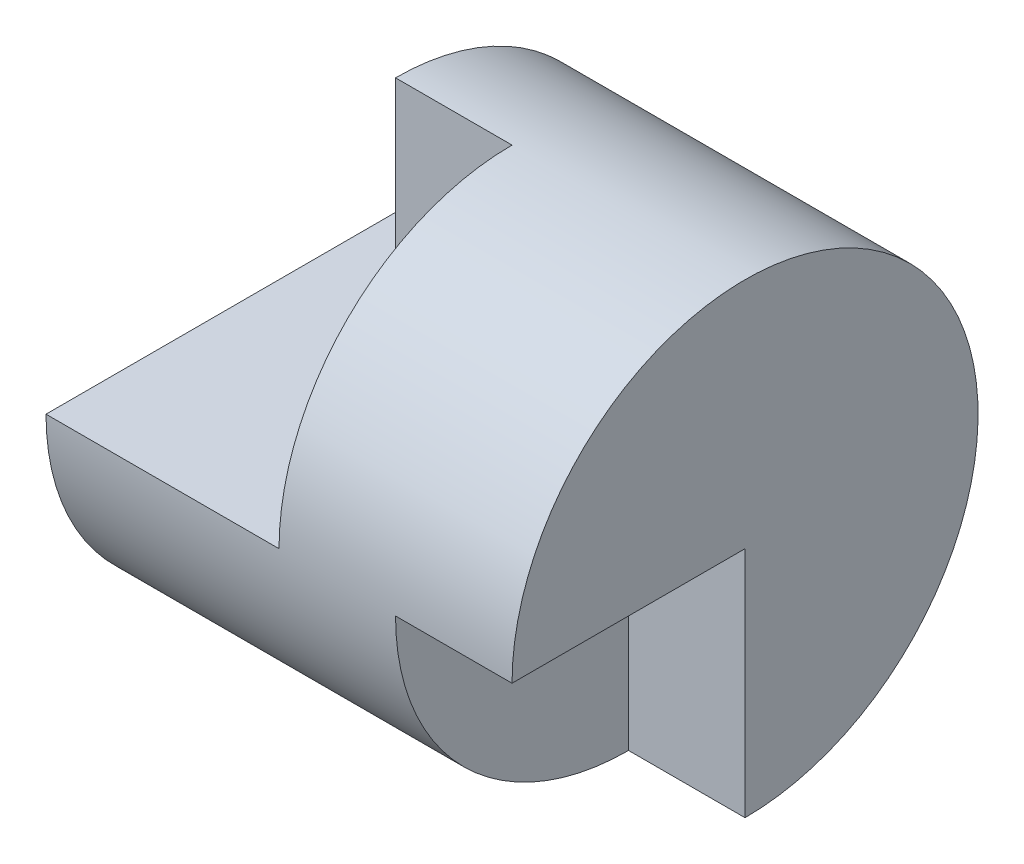
from build123d import *

# Parameters (mm, degrees)
SKETCH5_W           = 4
SKETCH5_H           = 2
SKETCH6_W           = 1
SKETCH6_H           = 2
CUT_EXTRUDE5_DEPTH  = 11
SKETCH8_W           = 0.5
SKETCH8_H           = 2
CUT_EXTRUDE7_DEPTH  = 10
SKETCH9_W           = 1.5
SKETCH9_H           = 2
CUT_EXTRUDE8_DEPTH  = 10
BOSS_EXTRUDE1_DEPTH = 1
SKETCH12_W          = 2.133602388
SKETCH12_H          = 2.324631101
CUT_EXTRUDE9_DEPTH  = 1


with BuildPart() as part:
    # Sketch5 → Revolve-Thin2 (revolve)
    with BuildSketch(Plane.XY):
        with Locations((2, 1)):
            Rectangle(SKETCH5_W, SKETCH5_H)
    revolve(axis=Axis((0, 0, 0), (1, 0, 0)))

    # Sketch6 → Cut-Extrude5 (cut)
    with BuildSketch(Plane.XY):
        with Locations((3.5, 1)):
            Rectangle(SKETCH6_W, SKETCH6_H)
        with Locations((0.5, 1)):
            Rectangle(SKETCH6_W, SKETCH6_H)
    extrude(amount=-CUT_EXTRUDE5_DEPTH, mode=Mode.SUBTRACT)

    # Sketch8 → Cut-Extrude7 (cut)
    with BuildSketch(Plane(origin=(0, 0, 0), x_dir=(-1, 0, 0), z_dir=(0, 0, -1))):
        with Locations((-0.25, 1)):
            Rectangle(SKETCH8_W, SKETCH8_H)
    extrude(amount=-CUT_EXTRUDE7_DEPTH, mode=Mode.SUBTRACT)

    # Sketch9 → Cut-Extrude8 (cut)
    with BuildSketch(Plane(origin=(0, 0, 0), x_dir=(-1, 0, 0), z_dir=(0, 0, -1))):
        with Locations((-1.25, 1)):
            Rectangle(SKETCH9_W, SKETCH9_H)
    extrude(amount=-CUT_EXTRUDE8_DEPTH, mode=Mode.SUBTRACT)

    # Sketch10 → Boss-Extrude1 (add)
    with BuildSketch(Plane(origin=(4, 0, 0), x_dir=(0, 0, -1), z_dir=(1, 0, 0))):
        with BuildLine():
            Line((2, 0), (-0.034977088, 0))
            Line((-0.034977088, 0), (0, 2))
            ThreePointArc((0, 2), (1.414213562, 1.414213562), (2, 0))
        make_face()
    extrude(amount=-BOSS_EXTRUDE1_DEPTH)

    # Sketch12 → Cut-Extrude9 (cut)
    with BuildSketch(Plane(origin=(4, 0, 0), x_dir=(0, 0, -1), z_dir=(1, 0, 0))):
        with Locations((-1.066801194, -1.162315551)):
            Rectangle(SKETCH12_W, SKETCH12_H)
    extrude(amount=-CUT_EXTRUDE9_DEPTH, mode=Mode.SUBTRACT)


solid = part.part
